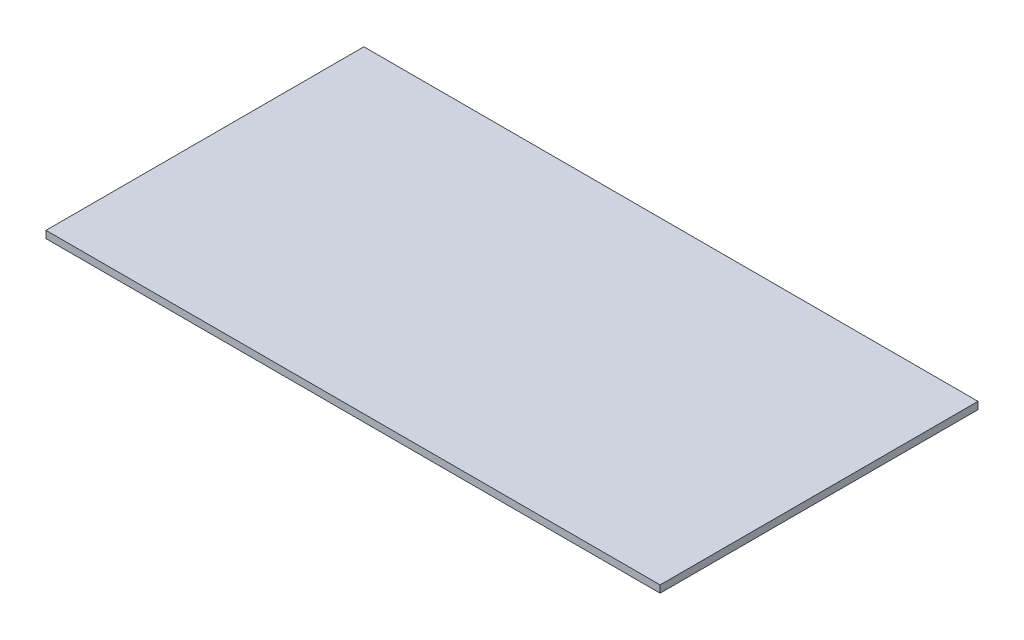
from build123d import *

# Parameters (mm, degrees)
SKETCH1_W           = 85
SKETCH1_H           = 44
BOSS_EXTRUDE1_DEPTH = 1


with BuildPart() as part:
    # Sketch1 → Boss-Extrude1 (new body)
    with BuildSketch(Plane(origin=(0, 0, 0), x_dir=(1, 0, 0), z_dir=(0, 1, 0))):
        with Locations((-1.053719008, -16.566115702)):
            Rectangle(SKETCH1_W, SKETCH1_H)
    extrude(amount=BOSS_EXTRUDE1_DEPTH)


solid = part.part
